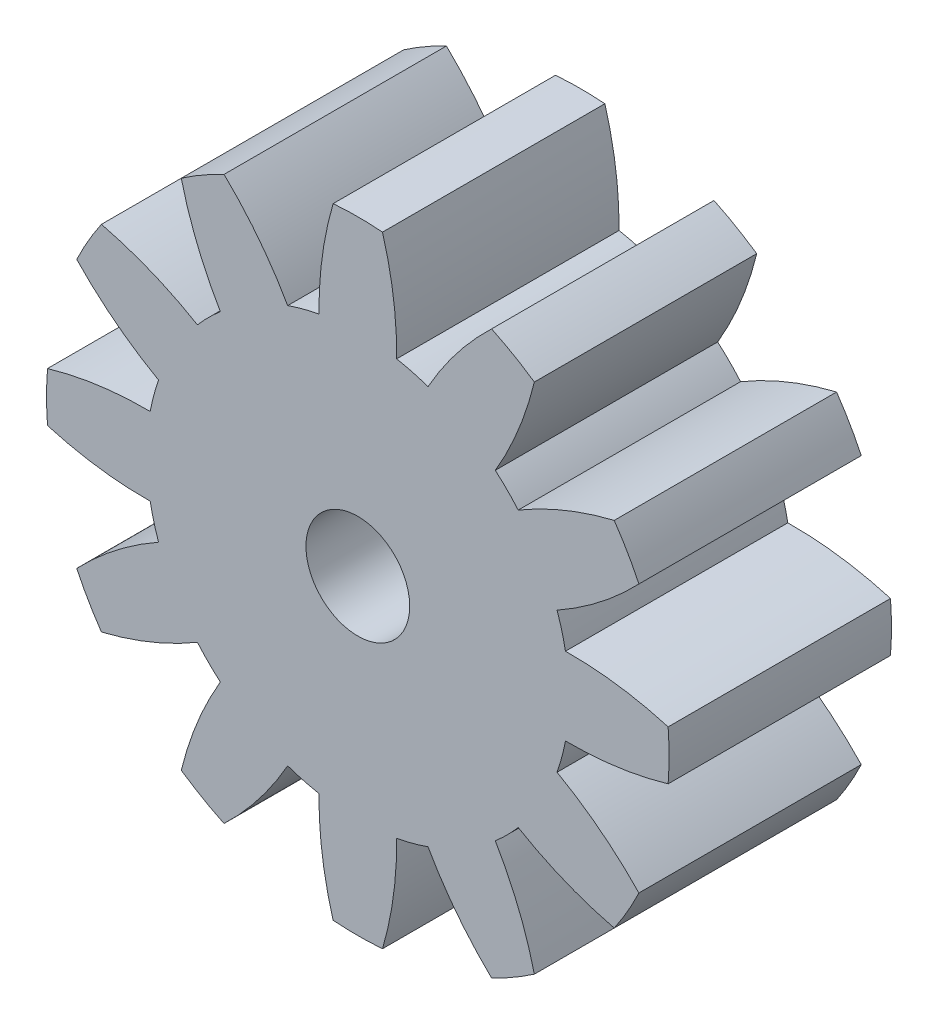
from build123d import *

# Parameters (mm, degrees)
SKETCH_1_R      = 0.35
EXTRUDE_1_DEPTH = 1.5


with BuildPart() as part:
    # 스케치1 → 보스-돌출1 (new body)
    with BuildSketch(Plane.XY):
        with BuildLine():
            ThreePointArc((-0.166490254, 2.093389834), (-0.239891186, 1.750579573), (-0.262040986, 1.400699654))
            ThreePointArc((-0.262040986, 1.400699654), (-0.368817139, 1.376444302), (-0.473415677, 1.344061977))
            ThreePointArc((-0.473415677, 1.344061977), (-0.667537925, 1.635991975), (-0.902510127, 1.896173903))
            ThreePointArc((-0.902510127, 1.896173903), (-1.05, 1.818653348), (-1.190879707, 1.729683649))
            ThreePointArc((-1.190879707, 1.729683649), (-1.083041648, 1.396100789), (-0.927283978, 1.082020991))
            ThreePointArc((-0.927283978, 1.082020991), (-1.007627163, 1.007627163), (-1.082020991, 0.927283978))
            ThreePointArc((-1.082020991, 0.927283978), (-1.396100789, 1.083041648), (-1.729683649, 1.190879707))
            ThreePointArc((-1.729683649, 1.190879707), (-1.818653348, 1.05), (-1.896173903, 0.902510127))
            ThreePointArc((-1.896173903, 0.902510127), (-1.635991975, 0.667537925), (-1.344061977, 0.473415677))
            ThreePointArc((-1.344061977, 0.473415677), (-1.376444302, 0.368817139), (-1.400699654, 0.262040986))
            ThreePointArc((-1.400699654, 0.262040986), (-1.750579573, 0.239891186), (-2.093389834, 0.166490254))
            ThreePointArc((-2.093389834, 0.166490254), (-2.1, 0), (-2.093389834, -0.166490254))
            ThreePointArc((-2.093389834, -0.166490254), (-1.750579573, -0.239891186), (-1.400699654, -0.262040986))
            ThreePointArc((-1.400699654, -0.262040986), (-1.376444302, -0.368817139), (-1.344061977, -0.473415677))
            ThreePointArc((-1.344061977, -0.473415677), (-1.635991975, -0.667537925), (-1.896173903, -0.902510127))
            ThreePointArc((-1.896173903, -0.902510127), (-1.818653348, -1.05), (-1.729683649, -1.190879707))
            ThreePointArc((-1.729683649, -1.190879707), (-1.396100789, -1.083041648), (-1.082020991, -0.927283978))
            ThreePointArc((-1.082020991, -0.927283978), (-1.007627163, -1.007627163), (-0.927283978, -1.082020991))
            ThreePointArc((-0.927283978, -1.082020991), (-1.083041648, -1.396100789), (-1.190879707, -1.729683649))
            ThreePointArc((-1.190879707, -1.729683649), (-1.05, -1.818653348), (-0.902510127, -1.896173903))
            ThreePointArc((-0.902510127, -1.896173903), (-0.667537925, -1.635991975), (-0.473415677, -1.344061977))
            ThreePointArc((-0.473415677, -1.344061977), (-0.368817139, -1.376444302), (-0.262040986, -1.400699654))
            ThreePointArc((-0.262040986, -1.400699654), (-0.239891186, -1.750579573), (-0.166490254, -2.093389834))
            ThreePointArc((-0.166490254, -2.093389834), (0, -2.1), (0.166490254, -2.093389834))
            ThreePointArc((0.166490254, -2.093389834), (0.239891186, -1.750579573), (0.262040986, -1.400699654))
            ThreePointArc((0.262040986, -1.400699654), (0.368817139, -1.376444302), (0.473415677, -1.344061977))
            ThreePointArc((0.473415677, -1.344061977), (0.667537925, -1.635991975), (0.902510127, -1.896173903))
            ThreePointArc((0.902510127, -1.896173903), (1.05, -1.818653348), (1.190879707, -1.729683649))
            ThreePointArc((1.190879707, -1.729683649), (1.083041648, -1.396100789), (0.927283978, -1.082020991))
            ThreePointArc((0.927283978, -1.082020991), (1.007627163, -1.007627163), (1.082020991, -0.927283978))
            ThreePointArc((1.082020991, -0.927283978), (1.396100789, -1.083041648), (1.729683649, -1.190879707))
            ThreePointArc((1.729683649, -1.190879707), (1.818653348, -1.05), (1.896173903, -0.902510127))
            ThreePointArc((1.896173903, -0.902510127), (1.635991975, -0.667537925), (1.344061977, -0.473415677))
            ThreePointArc((1.344061977, -0.473415677), (1.376444302, -0.368817139), (1.400699654, -0.262040986))
            ThreePointArc((1.400699654, -0.262040986), (1.750579573, -0.239891186), (2.093389834, -0.166490254))
            ThreePointArc((2.093389834, -0.166490254), (2.1, 0), (2.093389834, 0.166490254))
            ThreePointArc((2.093389834, 0.166490254), (1.750579573, 0.239891186), (1.400699654, 0.262040986))
            ThreePointArc((1.400699654, 0.262040986), (1.376444302, 0.368817139), (1.344061977, 0.473415677))
            ThreePointArc((1.344061977, 0.473415677), (1.635991975, 0.667537925), (1.896173903, 0.902510127))
            ThreePointArc((1.896173903, 0.902510127), (1.818653348, 1.05), (1.729683649, 1.190879707))
            ThreePointArc((1.729683649, 1.190879707), (1.396100789, 1.083041648), (1.082020991, 0.927283978))
            ThreePointArc((1.082020991, 0.927283978), (1.007627163, 1.007627163), (0.927283978, 1.082020991))
            ThreePointArc((0.927283978, 1.082020991), (1.083041648, 1.396100789), (1.190879707, 1.729683649))
            ThreePointArc((1.190879707, 1.729683649), (1.05, 1.818653348), (0.902510127, 1.896173903))
            ThreePointArc((0.902510127, 1.896173903), (0.667537925, 1.635991975), (0.473415677, 1.344061977))
            ThreePointArc((0.473415677, 1.344061977), (0.368817139, 1.376444302), (0.262040986, 1.400699654))
            ThreePointArc((0.262040986, 1.400699654), (0.239891186, 1.750579573), (0.166490254, 2.093389834))
            ThreePointArc((0.166490254, 2.093389834), (0, 2.1), (-0.166490254, 2.093389834))
        make_face()
        Circle(SKETCH_1_R, mode=Mode.SUBTRACT)
    extrude(amount=EXTRUDE_1_DEPTH)


solid = part.part
